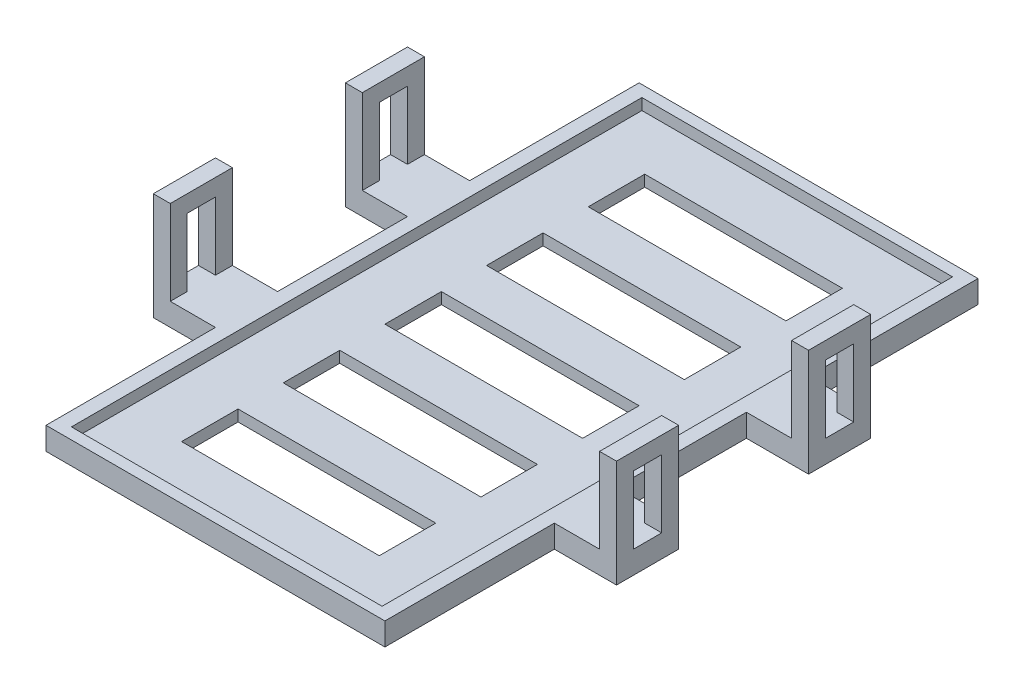
from build123d import *

# Parameters (mm, degrees)
SALIENTE_EXTRUIR1_DEPTH    = 4
CROQUIS2_W                 = 55
CROQUIS2_H                 = 101
CORTAR_EXTRUIR1_DEPTH      = 2
CROQUIS12_W                = 3
CROQUIS12_H                = 11
SALIENTE_EXTRUIR2_DEPTH    = 15
CROQUIS13_W                = 5
CROQUIS13_H                = 12
CORTAR_EXTRUIR8_DEPTH      = 80
CORTAR_EXTRUIR8_DEPTH_BACK = 4
CROQUIS14_W                = 5
CROQUIS14_H                = 12
CORTAR_EXTRUIR9_DEPTH      = 80
CORTAR_EXTRUIR9_DEPTH_BACK = 4
CROQUIS15_W                = 35
CROQUIS15_H                = 10
CORTAR_EXTRUIR10_DEPTH     = 20


with BuildPart() as part:
    # Croquis1 → Saliente-Extruir1 (new body)
    with BuildSketch(Plane(origin=(0, 0, 0), x_dir=(1, 0, 0), z_dir=(0, 1, 0))):
        Polygon((30, -52.5), (30, -22.5), (41, -22.5), (41, -11.5), (30, -11.5), (30, 11.5), (41, 11.5), (41, 22.5), (30, 22.5), (30, 52.5), (-30, 52.5), (-30, 22.5), (-41, 22.5), (-41, 11.5), (-30, 11.5), (-30, -11.5), (-41, -11.5), (-41, -22.5), (-30, -22.5), (-30, -52.5), align=None)
    extrude(amount=SALIENTE_EXTRUIR1_DEPTH)

    # Croquis2 → Cortar-Extruir1 (cut)
    with BuildSketch(Plane(origin=(0, 4, 0), x_dir=(1, 0, 0), z_dir=(0, 1, 0))):
        Rectangle(CROQUIS2_W, CROQUIS2_H)
    extrude(amount=-CORTAR_EXTRUIR1_DEPTH, mode=Mode.SUBTRACT)

    # Croquis12 → Saliente-Extruir2 (add)
    with BuildSketch(Plane(origin=(0, 4, 0), x_dir=(1, 0, 0), z_dir=(0, 1, 0))):
        with Locations((-39.5, 17)):
            Rectangle(CROQUIS12_W, CROQUIS12_H)
        with Locations((-39.5, -17)):
            Rectangle(CROQUIS12_W, CROQUIS12_H)
        with Locations((39.5, -17)):
            Rectangle(CROQUIS12_W, CROQUIS12_H)
        with Locations((39.5, 17)):
            Rectangle(CROQUIS12_W, CROQUIS12_H)
    extrude(amount=SALIENTE_EXTRUIR2_DEPTH)

    # Croquis13 → Cortar-Extruir8 (cut, two sides)
    with BuildSketch(Plane.ZY.offset(-38)) as cortar_extruir8_sk:
        with Locations((-17, 10)):
            Rectangle(CROQUIS13_W, CROQUIS13_H)
    extrude(amount=CORTAR_EXTRUIR8_DEPTH, mode=Mode.SUBTRACT)
    extrude(cortar_extruir8_sk.sketch, amount=-CORTAR_EXTRUIR8_DEPTH_BACK, mode=Mode.SUBTRACT)

    # Croquis14 → Cortar-Extruir9 (cut, two sides)
    with BuildSketch(Plane.ZY.offset(-38)) as cortar_extruir9_sk:
        with Locations((17, 10)):
            Rectangle(CROQUIS14_W, CROQUIS14_H)
    extrude(amount=CORTAR_EXTRUIR9_DEPTH, mode=Mode.SUBTRACT)
    extrude(cortar_extruir9_sk.sketch, amount=-CORTAR_EXTRUIR9_DEPTH_BACK, mode=Mode.SUBTRACT)

    # Croquis15 → Cortar-Extruir10 (cut, through all)
    with BuildSketch(Plane(origin=(0, 0, 0), x_dir=(1, 0, 0), z_dir=(0, 1, 0))):
        Rectangle(CROQUIS15_W, CROQUIS15_H)
        with Locations((0, -18)):
            Rectangle(CROQUIS15_W, CROQUIS15_H)
        with Locations((0, -36)):
            Rectangle(CROQUIS15_W, CROQUIS15_H)
        with Locations((0, 18)):
            Rectangle(CROQUIS15_W, CROQUIS15_H)
        with Locations((0, 36)):
            Rectangle(CROQUIS15_W, CROQUIS15_H)
    extrude(amount=CORTAR_EXTRUIR10_DEPTH, mode=Mode.SUBTRACT)


solid = part.part
